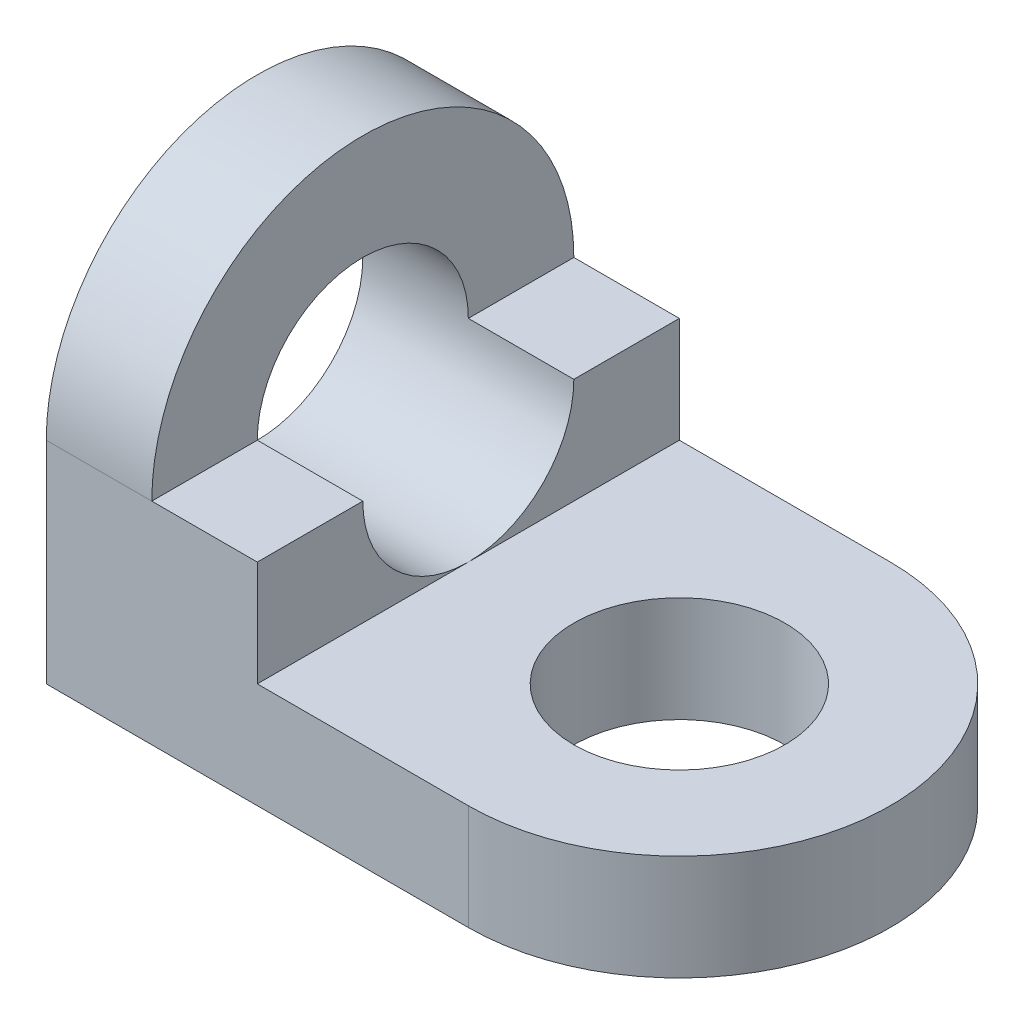
from build123d import *

# Parameters (mm, degrees)
SKETCH_1_R      = 1
EXTRUDE_1_DEPTH = 1
SKETCH_2_R      = 1
EXTRUDE_3_DEPTH = 1
EXTRUDE_4_DEPTH = 2


with BuildPart() as part:
    # 草圖1 → 填料-伸長1 (new body)
    with BuildSketch(Plane(origin=(0, 0, 0), x_dir=(1, 0, 0), z_dir=(0, 1, 0))):
        with BuildLine():
            Line((4, 2), (0, 2))
            Line((0, 2), (0, -2))
            Line((0, -2), (4, -2))
            ThreePointArc((4, -2), (6, 0), (4, 2))
        make_face()
        with Locations((4, 0)):
            Circle(SKETCH_1_R, mode=Mode.SUBTRACT)
    extrude(amount=EXTRUDE_1_DEPTH)

    # 草圖2 → 填料-伸長3 (add)
    with BuildSketch(Plane(origin=(0, 0, 0), x_dir=(0, 0, -1), z_dir=(1, 0, 0))):
        with BuildLine():
            Line((-2, 2), (-2, 0))
            Line((-2, 0), (2, 0))
            Line((2, 0), (2, 2))
            ThreePointArc((2, 2), (0, 4), (-2, 2))
        make_face()
        with Locations((0, 2)):
            Circle(SKETCH_2_R, mode=Mode.SUBTRACT)
    extrude(amount=EXTRUDE_3_DEPTH)

    # 草圖2<4> → 填料-伸長4 (add)
    with BuildSketch(Plane(origin=(0, 0, 0), x_dir=(0, 0, -1), z_dir=(1, 0, 0))):
        with BuildLine():
            Line((-1, 2), (-2, 2))
            Line((-2, 2), (-2, 0))
            Line((-2, 0), (2, 0))
            Line((2, 0), (2, 2))
            Line((2, 2), (1, 2))
            ThreePointArc((1, 2), (0, 1), (-1, 2))
        make_face()
    extrude(amount=EXTRUDE_4_DEPTH)


solid = part.part
